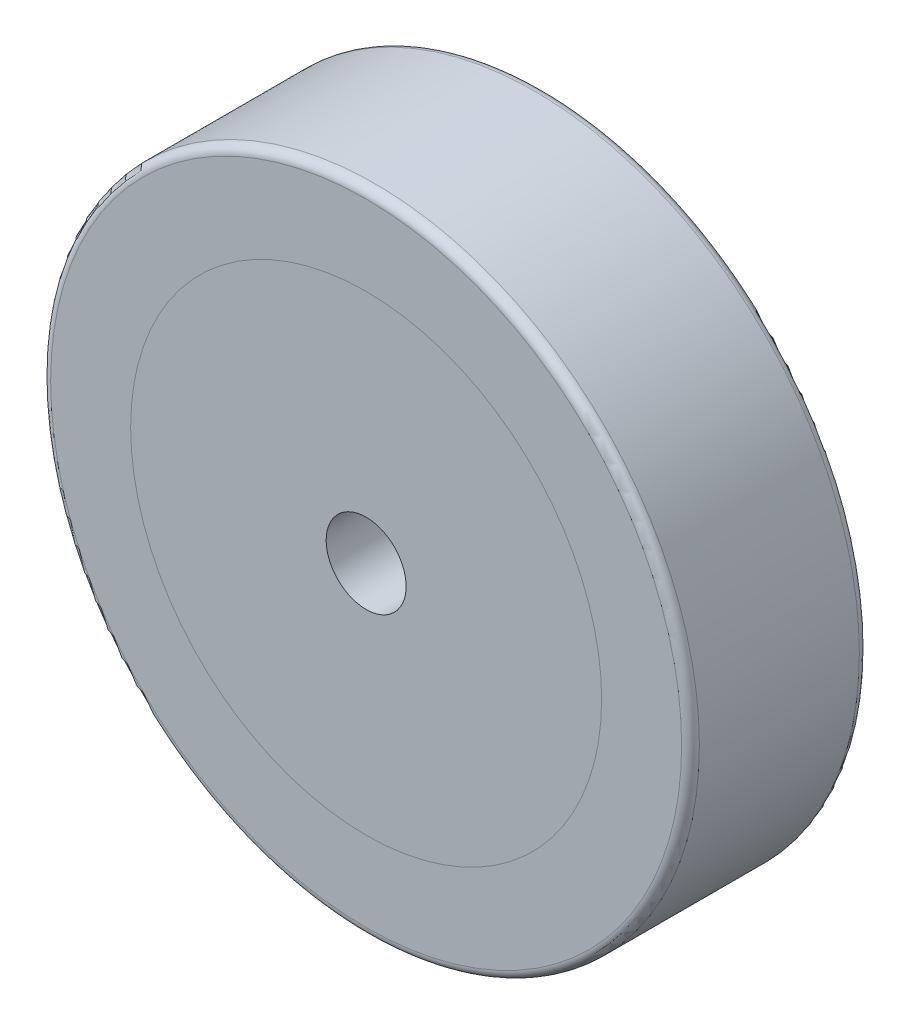
from build123d import *

# Parameters (mm, degrees)
ESQUISSE1_R             = 36.5
BOSS_EXTRU_1_DEPTH      = 20
ESQUISSE2_R             = 26.5
ENL_V_MAT_EXTRU_2_DEPTH = 20
ESQUISSE4_R             = 26.5
BOSS_EXTRU_3_DEPTH      = 20
ESQUISSE9_W             = 4.5
ESQUISSE9_H             = 20
CONG_1_R                = 1


with BuildPart() as part:
    # Esquisse1 → Boss.-Extru.1 (new body)
    with BuildSketch(Plane.XY):
        Circle(ESQUISSE1_R)
    extrude(amount=BOSS_EXTRU_1_DEPTH)

    # Esquisse2 → Enlèv. mat.-Extru.2 (cut)
    with BuildSketch(Plane.XY.offset(20)):
        Circle(ESQUISSE2_R)
    extrude(amount=-ENL_V_MAT_EXTRU_2_DEPTH, mode=Mode.SUBTRACT)

    # Congé1
    cong_1_edges = [part.edges().sort_by_distance(p)[0] for p in [
        (-36.5, 0, 0),
        (-36.5, 0, 20),
    ]]
    fillet(cong_1_edges, radius=CONG_1_R)


with BuildPart() as body_2:
    # Esquisse4 → Boss.-Extru.3 (new body)
    with BuildSketch(Plane.XY.offset(20)):
        Circle(ESQUISSE4_R)
    extrude(amount=-BOSS_EXTRU_3_DEPTH)

    # Esquisse9 → Dégagement M81 (revolve, cut)
    with BuildSketch(Plane.YZ):
        with Locations((2.25, 10)):
            Rectangle(ESQUISSE9_W, ESQUISSE9_H)
    revolve(axis=Axis((0, 0, -6.35), (0, 0, 1)), mode=Mode.SUBTRACT)


solid = Compound([part.part, body_2.part])
